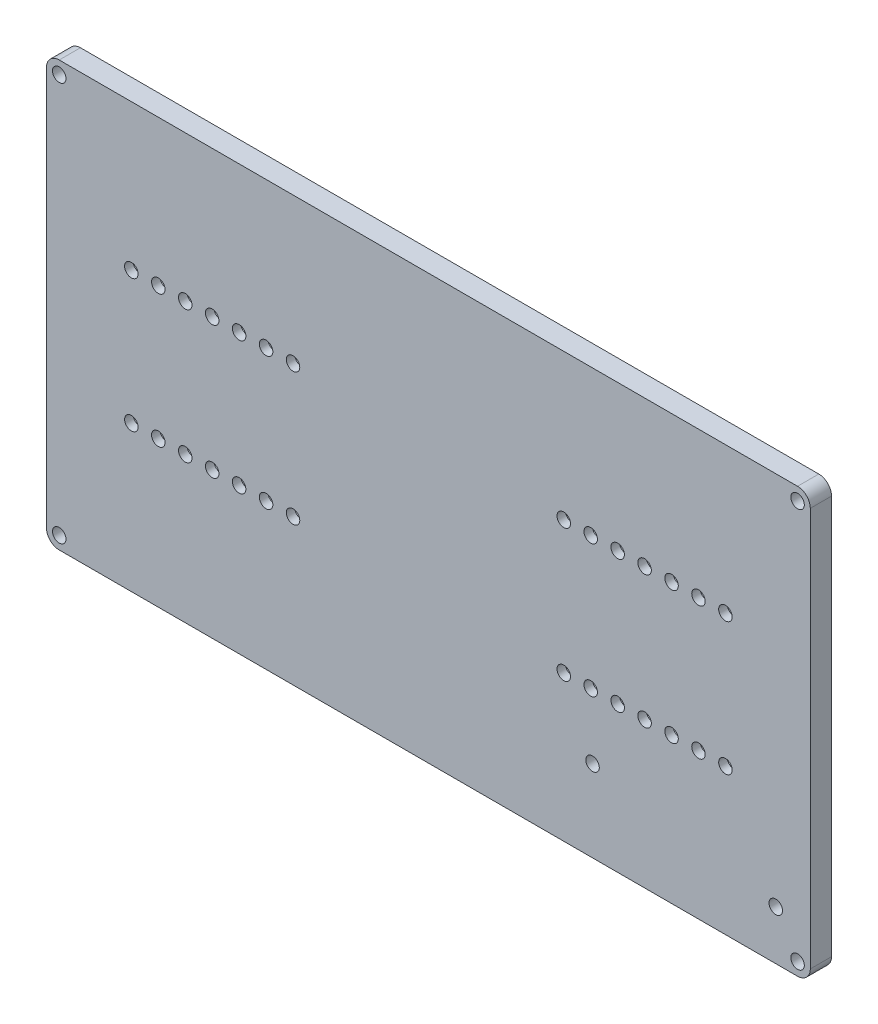
from build123d import *

# Parameters (mm, degrees)
SKETCH1_W                = 180
SKETCH1_H                = 100
BOSS_EXTRUDE1_DEPTH      = 5
SKETCH2_R                = 1.59
CUT_EXTRUDE1_DEPTH       = 6
LPATTERN1_COUNT          = 7
LPATTERN1_PITCH          = 6.35
LPATTERN1_COUNT_DIR2     = 2
LPATTERN1_PITCH_DIR2     = 31.24
MIRROR1_COPY_1_SKETCH_R  = 1.59
MIRROR1_COPY_1_DEPTH     = 6
MIRROR1_COPY_2_SKETCH_R  = 1.59
MIRROR1_COPY_2_DEPTH     = 6
MIRROR1_COPY_3_SKETCH_R  = 1.59
MIRROR1_COPY_3_DEPTH     = 6
MIRROR1_COPY_4_SKETCH_R  = 1.59
MIRROR1_COPY_4_DEPTH     = 6
MIRROR1_COPY_5_SKETCH_R  = 1.59
MIRROR1_COPY_5_DEPTH     = 6
MIRROR1_COPY_6_SKETCH_R  = 1.59
MIRROR1_COPY_6_DEPTH     = 6
MIRROR1_COPY_7_SKETCH_R  = 1.59
MIRROR1_COPY_7_DEPTH     = 6
MIRROR1_COPY_8_SKETCH_R  = 1.59
MIRROR1_COPY_8_DEPTH     = 6
MIRROR1_COPY_9_SKETCH_R  = 1.59
MIRROR1_COPY_9_DEPTH     = 6
MIRROR1_COPY_10_SKETCH_R = 1.59
MIRROR1_COPY_10_DEPTH    = 6
MIRROR1_COPY_11_SKETCH_R = 1.59
MIRROR1_COPY_11_DEPTH    = 6
MIRROR1_COPY_12_SKETCH_R = 1.59
MIRROR1_COPY_12_DEPTH    = 6
MIRROR1_COPY_13_SKETCH_R = 1.59
MIRROR1_COPY_13_DEPTH    = 6
SKETCH4_W                = 44.1
SKETCH4_H                = 5.2
CUT_EXTRUDE3_DEPTH       = 3
MIRROR5_COPY_1_SKETCH_W  = 44.1
MIRROR5_COPY_1_SKETCH_H  = 5.2
MIRROR5_COPY_1_DEPTH     = 3
FILLET1_R                = 1
FILLET2_R                = 3
SKETCH5_R                = 3
BOSS_EXTRUDE3_DEPTH      = 3
SKETCH11_R               = 1.59
CUT_EXTRUDE5_DEPTH       = 1
CUT_EXTRUDE5_DEPTH_BACK  = 9
SKETCH12_R               = 1.59
CUT_EXTRUDE6_DEPTH       = 4
CUT_EXTRUDE6_DEPTH_BACK  = 6
SKETCH14_R               = 3
CUT_EXTRUDE7_DEPTH       = 4
CUT_EXTRUDE8_DEPTH       = 0.4


with BuildPart() as part:
    # Sketch1 → Boss-Extrude1 (new body)
    with BuildSketch(Plane.XY):
        Rectangle(SKETCH1_W, SKETCH1_H)
    extrude(amount=BOSS_EXTRUDE1_DEPTH)

    # Sketch2 → Cut-Extrude1 (cut, through all)
    with BuildSketch(Plane.XY.offset(5)):
        with Locations((-70, 15.62)):
            Circle(SKETCH2_R)
    cut_extrude1 = extrude(amount=-CUT_EXTRUDE1_DEPTH, mode=Mode.SUBTRACT)

    # LPattern1: Cut-Extrude1 7 × 2
    with Locations(*[(i * LPATTERN1_PITCH, -j * LPATTERN1_PITCH_DIR2, 0) for i in range(LPATTERN1_COUNT) for j in range(LPATTERN1_COUNT_DIR2) if (i, j) != (0, 0)]):
        add(cut_extrude1, mode=Mode.SUBTRACT)

    # Mirror1: Cut-Extrude1 across plane
    add(cut_extrude1.mirror(Plane(origin=(0, 0, 0), x_dir=(0, 0, 1), z_dir=(1, 0, 0))), mode=Mode.SUBTRACT)

    # Mirror1 copy 1 sketch → Mirror1 copy 1 (cut, through all)
    with BuildSketch(Plane(origin=(0, -31.24, 5), x_dir=(-1, 0, 0), z_dir=(0, 0, 1))):
        with Locations((-70, -15.62)):
            Circle(MIRROR1_COPY_1_SKETCH_R)
    extrude(amount=-MIRROR1_COPY_1_DEPTH, mode=Mode.SUBTRACT)

    # Mirror1 copy 2 sketch → Mirror1 copy 2 (cut, through all)
    with BuildSketch(Plane(origin=(-6.35, 0, 5), x_dir=(-1, 0, 0), z_dir=(0, 0, 1))):
        with Locations((-70, -15.62)):
            Circle(MIRROR1_COPY_2_SKETCH_R)
    extrude(amount=-MIRROR1_COPY_2_DEPTH, mode=Mode.SUBTRACT)

    # Mirror1 copy 3 sketch → Mirror1 copy 3 (cut, through all)
    with BuildSketch(Plane(origin=(-6.35, -31.24, 5), x_dir=(-1, 0, 0), z_dir=(0, 0, 1))):
        with Locations((-70, -15.62)):
            Circle(MIRROR1_COPY_3_SKETCH_R)
    extrude(amount=-MIRROR1_COPY_3_DEPTH, mode=Mode.SUBTRACT)

    # Mirror1 copy 4 sketch → Mirror1 copy 4 (cut, through all)
    with BuildSketch(Plane(origin=(-12.7, 0, 5), x_dir=(-1, 0, 0), z_dir=(0, 0, 1))):
        with Locations((-70, -15.62)):
            Circle(MIRROR1_COPY_4_SKETCH_R)
    extrude(amount=-MIRROR1_COPY_4_DEPTH, mode=Mode.SUBTRACT)

    # Mirror1 copy 5 sketch → Mirror1 copy 5 (cut, through all)
    with BuildSketch(Plane(origin=(-12.7, -31.24, 5), x_dir=(-1, 0, 0), z_dir=(0, 0, 1))):
        with Locations((-70, -15.62)):
            Circle(MIRROR1_COPY_5_SKETCH_R)
    extrude(amount=-MIRROR1_COPY_5_DEPTH, mode=Mode.SUBTRACT)

    # Mirror1 copy 6 sketch → Mirror1 copy 6 (cut, through all)
    with BuildSketch(Plane(origin=(-19.05, 0, 5), x_dir=(-1, 0, 0), z_dir=(0, 0, 1))):
        with Locations((-70, -15.62)):
            Circle(MIRROR1_COPY_6_SKETCH_R)
    extrude(amount=-MIRROR1_COPY_6_DEPTH, mode=Mode.SUBTRACT)

    # Mirror1 copy 7 sketch → Mirror1 copy 7 (cut, through all)
    with BuildSketch(Plane(origin=(-19.05, -31.24, 5), x_dir=(-1, 0, 0), z_dir=(0, 0, 1))):
        with Locations((-70, -15.62)):
            Circle(MIRROR1_COPY_7_SKETCH_R)
    extrude(amount=-MIRROR1_COPY_7_DEPTH, mode=Mode.SUBTRACT)

    # Mirror1 copy 8 sketch → Mirror1 copy 8 (cut, through all)
    with BuildSketch(Plane(origin=(-25.4, 0, 5), x_dir=(-1, 0, 0), z_dir=(0, 0, 1))):
        with Locations((-70, -15.62)):
            Circle(MIRROR1_COPY_8_SKETCH_R)
    extrude(amount=-MIRROR1_COPY_8_DEPTH, mode=Mode.SUBTRACT)

    # Mirror1 copy 9 sketch → Mirror1 copy 9 (cut, through all)
    with BuildSketch(Plane(origin=(-25.4, -31.24, 5), x_dir=(-1, 0, 0), z_dir=(0, 0, 1))):
        with Locations((-70, -15.62)):
            Circle(MIRROR1_COPY_9_SKETCH_R)
    extrude(amount=-MIRROR1_COPY_9_DEPTH, mode=Mode.SUBTRACT)

    # Mirror1 copy 10 sketch → Mirror1 copy 10 (cut, through all)
    with BuildSketch(Plane(origin=(-31.75, 0, 5), x_dir=(-1, 0, 0), z_dir=(0, 0, 1))):
        with Locations((-70, -15.62)):
            Circle(MIRROR1_COPY_10_SKETCH_R)
    extrude(amount=-MIRROR1_COPY_10_DEPTH, mode=Mode.SUBTRACT)

    # Mirror1 copy 11 sketch → Mirror1 copy 11 (cut, through all)
    with BuildSketch(Plane(origin=(-31.75, -31.24, 5), x_dir=(-1, 0, 0), z_dir=(0, 0, 1))):
        with Locations((-70, -15.62)):
            Circle(MIRROR1_COPY_11_SKETCH_R)
    extrude(amount=-MIRROR1_COPY_11_DEPTH, mode=Mode.SUBTRACT)

    # Mirror1 copy 12 sketch → Mirror1 copy 12 (cut, through all)
    with BuildSketch(Plane(origin=(-38.1, 0, 5), x_dir=(-1, 0, 0), z_dir=(0, 0, 1))):
        with Locations((-70, -15.62)):
            Circle(MIRROR1_COPY_12_SKETCH_R)
    extrude(amount=-MIRROR1_COPY_12_DEPTH, mode=Mode.SUBTRACT)

    # Mirror1 copy 13 sketch → Mirror1 copy 13 (cut, through all)
    with BuildSketch(Plane(origin=(-38.1, -31.24, 5), x_dir=(-1, 0, 0), z_dir=(0, 0, 1))):
        with Locations((-70, -15.62)):
            Circle(MIRROR1_COPY_13_SKETCH_R)
    extrude(amount=-MIRROR1_COPY_13_DEPTH, mode=Mode.SUBTRACT)

    # Sketch4 → Cut-Extrude3 (cut)
    with BuildSketch(Plane(origin=(0, 0, 0), x_dir=(-1, 0, 0), z_dir=(0, 0, -1))):
        with Locations((50.95, 15.62)):
            Rectangle(SKETCH4_W, SKETCH4_H)
    cut_extrude3 = extrude(amount=-CUT_EXTRUDE3_DEPTH, mode=Mode.SUBTRACT)

    # Mirror4: Cut-Extrude3 across plane
    add(cut_extrude3.mirror(Plane.ZX), mode=Mode.SUBTRACT)

    # Mirror5: Cut-Extrude3 across plane
    add(cut_extrude3.mirror(Plane(origin=(0, 0, 0), x_dir=(0, 0, 1), z_dir=(1, 0, 0))), mode=Mode.SUBTRACT)

    # Mirror5 copy 1 sketch → Mirror5 copy 1 (cut)
    with BuildSketch(Plane(origin=(0, 0, 0), x_dir=(1, 0, 0), z_dir=(0, 0, -1))):
        with Locations((50.95, 15.62)):
            Rectangle(MIRROR5_COPY_1_SKETCH_W, MIRROR5_COPY_1_SKETCH_H)
    extrude(amount=-MIRROR5_COPY_1_DEPTH, mode=Mode.SUBTRACT)

    # Fillet1
    fillet1_edges = [part.edges().sort_by_distance(p)[0] for p in [
        (-28.9, 13.02, 1.5),
        (-28.9, 18.22, 1.5),
        (-73, 18.22, 1.5),
        (-73, 13.02, 1.5),
        (-28.9, -18.22, 1.5),
        (-28.9, -13.02, 1.5),
        (-73, -13.02, 1.5),
        (-73, -18.22, 1.5),
        (28.9, -13.02, 1.5),
        (28.9, -18.22, 1.5),
        (73, -18.22, 1.5),
        (73, -13.02, 1.5),
        (28.9, 18.22, 1.5),
        (28.9, 13.02, 1.5),
        (73, 13.02, 1.5),
        (73, 18.22, 1.5),
    ]]
    fillet(fillet1_edges, radius=FILLET1_R)

    # Fillet2
    fillet2_edges = [part.edges().sort_by_distance(p)[0] for p in [
        (-90, 50, 2.5),
        (90, 50, 2.5),
        (90, -50, 2.5),
        (-90, -50, 2.5),
    ]]
    fillet(fillet2_edges, radius=FILLET2_R)

    # Sketch5 → Boss-Extrude3 (add)
    with BuildSketch(Plane(origin=(0, 0, 0), x_dir=(-1, 0, 0), z_dir=(0, 0, -1))):
        with Locations((-81.863597073, -38.398306499)):
            Circle(SKETCH5_R)
        with Locations((-38.683597073, -30.778306499)):
            Circle(SKETCH5_R)
    extrude(amount=BOSS_EXTRUDE3_DEPTH)

    # Sketch11 → Cut-Extrude5 (cut, two sides)
    with BuildSketch(Plane(origin=(0, 0, -3), x_dir=(-1, 0, 0), z_dir=(0, 0, -1))) as cut_extrude5_sk:
        with Locations((-81.863597073, -38.398306499)):
            Circle(SKETCH11_R)
        with Locations((-38.683597073, -30.778306499)):
            Circle(SKETCH11_R)
    extrude(amount=CUT_EXTRUDE5_DEPTH, mode=Mode.SUBTRACT)
    extrude(cut_extrude5_sk.sketch, amount=-CUT_EXTRUDE5_DEPTH_BACK, mode=Mode.SUBTRACT)

    # Sketch12 → Cut-Extrude6 (cut, two sides)
    with BuildSketch(Plane(origin=(0, 0, 0), x_dir=(-1, 0, 0), z_dir=(0, 0, -1))) as cut_extrude6_sk:
        with Locations((-87, -47)):
            Circle(SKETCH12_R)
        with Locations((-87, 47)):
            Circle(SKETCH12_R)
        with Locations((87, 47)):
            Circle(SKETCH12_R)
        with Locations((87, -47)):
            Circle(SKETCH12_R)
    extrude(amount=CUT_EXTRUDE6_DEPTH, mode=Mode.SUBTRACT)
    extrude(cut_extrude6_sk.sketch, amount=-CUT_EXTRUDE6_DEPTH_BACK, mode=Mode.SUBTRACT)

    # Sketch14 → Cut-Extrude7 (cut)
    with BuildSketch(Plane(origin=(0, 0, 0), x_dir=(-1, 0, 0), z_dir=(0, 0, -1))):
        with BuildLine():
            ThreePointArc((-85.348265181, 49), (-84.514110663, 47.740663297), (-84.522995338, 46.230145586))
            Line((-84.522995338, 46.230145586), (-34.525491807, 19.22))
            Line((-34.525491807, 19.22), (-29.9, 19.22))
            ThreePointArc((-29.9, 19.22), (-28.485786438, 18.634213562), (-27.9, 17.22))
            Line((-27.9, 17.22), (-27.9, 15.640711323))
            Line((-27.9, 15.640711323), (-0.79625872, 0.998460287))
            Line((-0.79625872, 0.998460287), (0.796309268, 0.998487594))
            Line((0.796309268, 0.998487594), (27.9, 15.640711323))
            Line((27.9, 15.640711323), (27.9, 17.22))
            ThreePointArc((27.9, 17.22), (28.485786438, 18.634213562), (29.9, 19.22))
            Line((29.9, 19.22), (34.525491807, 19.22))
            Line((34.525491807, 19.22), (84.526476888, 46.232026423))
            ThreePointArc((84.526476888, 46.232026423), (84.518614054, 47.742175039), (85.354369422, 49))
            Line((85.354369422, 49), (-85.348265181, 49))
        make_face()
        with BuildLine():
            Line((36.62940181, -19.22), (85.00178239, -45.352205601))
            ThreePointArc((85.00178239, -45.352205601), (87.001401699, -44.410000379), (89, -45.354369422))
            Line((89, -45.354369422), (89, -1))
            Line((89, -1), (2.905751439, -1.001476236))
            Line((2.905751439, -1.001476236), (27.9, -14.504116263))
            Line((27.9, -14.504116263), (27.9, -14.02))
            ThreePointArc((27.9, -14.02), (28.485786438, -12.605786438), (29.9, -12.02))
            Line((29.9, -12.02), (72, -12.02))
            ThreePointArc((72, -12.02), (73.414213562, -12.605786438), (74, -14.02))
            Line((74, -14.02), (74, -17.22))
            ThreePointArc((74, -17.22), (73.414213562, -18.634213562), (72, -19.22))
            Line((72, -19.22), (36.62940181, -19.22))
        make_face()
        with BuildLine():
            ThreePointArc((89, 45.354369422), (87.001401699, 44.410000379), (85.00178239, 45.352205601))
            Line((85.00178239, 45.352205601), (36.62940181, 19.22))
            Line((36.62940181, 19.22), (72, 19.22))
            ThreePointArc((72, 19.22), (73.414213562, 18.634213562), (74, 17.22))
            Line((74, 17.22), (74, 14.02))
            ThreePointArc((74, 14.02), (73.414213562, 12.605786438), (72, 12.02))
            Line((72, 12.02), (29.9, 12.02))
            ThreePointArc((29.9, 12.02), (28.485786438, 12.605786438), (27.9, 14.02))
            Line((27.9, 14.02), (27.9, 14.504116263))
            Line((27.9, 14.504116263), (2.900286051, 0.99852367))
            Line((2.900286051, 0.99852367), (89, 1))
            Line((89, 1), (89, 45.354369422))
        make_face()
        with BuildLine():
            Line((-2.9059359, -1.001575888), (-89, -1.003052121))
            Line((-89, -1.003052121), (-89, -45.354369422))
            ThreePointArc((-89, -45.354369422), (-87.001401699, -44.410000379), (-85.00178239, -45.352205601))
            Line((-85.00178239, -45.352205601), (-36.62940181, -19.22))
            Line((-36.62940181, -19.22), (-72, -19.22))
            ThreePointArc((-72, -19.22), (-73.414213562, -18.634213562), (-74, -17.22))
            Line((-74, -17.22), (-74, -14.02))
            ThreePointArc((-74, -14.02), (-73.414213562, -12.605786438), (-72, -12.02))
            Line((-72, -12.02), (-29.9, -12.02))
            ThreePointArc((-29.9, -12.02), (-28.485786438, -12.605786438), (-27.9, -14.02))
            Line((-27.9, -14.02), (-27.9, -14.504116263))
            Line((-27.9, -14.504116263), (-2.9059359, -1.001575888))
        make_face()
        with Locations((-81.863597073, -38.398306499)):
            Circle(SKETCH14_R, mode=Mode.SUBTRACT)
        with BuildLine():
            Line((-34.525491807, -19.22), (-84.526476888, -46.232026423))
            ThreePointArc((-84.526476888, -46.232026423), (-84.518614054, -47.742175039), (-85.354369422, -49))
            Line((-85.354369422, -49), (85.354369422, -49))
            ThreePointArc((85.354369422, -49), (84.518614054, -47.742175039), (84.526476888, -46.232026423))
            Line((84.526476888, -46.232026423), (34.525491807, -19.22))
            Line((34.525491807, -19.22), (29.9, -19.22))
            ThreePointArc((29.9, -19.22), (28.485786438, -18.634213562), (27.9, -17.22))
            Line((27.9, -17.22), (27.9, -15.640711323))
            Line((27.9, -15.640711323), (0.801908211, -1.00151231))
            Line((0.801908211, -1.00151231), (-0.801959117, -1.001539811))
            Line((-0.801959117, -1.001539811), (-27.9, -15.640711323))
            Line((-27.9, -15.640711323), (-27.9, -17.22))
            ThreePointArc((-27.9, -17.22), (-28.485786438, -18.634213562), (-29.9, -19.22))
            Line((-29.9, -19.22), (-34.525491807, -19.22))
        make_face()
        with Locations((-38.683597073, -30.778306499)):
            Circle(SKETCH14_R, mode=Mode.SUBTRACT)
        with BuildLine():
            ThreePointArc((-84.99830084, 45.350324763), (-86.998664988, 44.406117556), (-89, 45.348265181))
            Line((-89, 45.348265181), (-89, 0.99694788))
            Line((-89, 0.99694788), (-2.900101948, 0.998424213))
            Line((-2.900101948, 0.998424213), (-27.9, 14.504116263))
            Line((-27.9, 14.504116263), (-27.9, 14.02))
            ThreePointArc((-27.9, 14.02), (-28.485786438, 12.605786438), (-29.9, 12.02))
            Line((-29.9, 12.02), (-72, 12.02))
            ThreePointArc((-72, 12.02), (-73.414213562, 12.605786438), (-74, 14.02))
            Line((-74, 14.02), (-74, 17.22))
            ThreePointArc((-74, 17.22), (-73.414213562, 18.634213562), (-72, 19.22))
            Line((-72, 19.22), (-36.62940181, 19.22))
            Line((-36.62940181, 19.22), (-84.99830084, 45.350324763))
        make_face()
    extrude(amount=-CUT_EXTRUDE7_DEPTH, mode=Mode.SUBTRACT)

    # Sketch15 → Cut-Extrude8 (cut)
    with BuildSketch(Plane(origin=(0, 0, 4), x_dir=(-1, 0, 0), z_dir=(0, 0, -1))):
        with BuildLine():
            Line((69.307829408, 47.924379364), (70.006425423, 46.292812335))
            add(Edge.make_bspline(
                [(70.006425423, 46.292812335), (70.023413138, 46.255584111), (70.056423518, 46.183242549), (70.123321318, 46.087798721), (70.198897769, 46.005525039), (70.285383741, 45.937760562), (70.38281428, 45.887648882), (70.487055268, 45.848851983), (70.600032397, 45.82793733), (70.677771544, 45.824622904), (70.717476147, 45.822930089)],
                knots=[0, 0, 0, 0, 0.000122539, 0.000238117, 0.000347875, 0.000456812, 0.000565708, 0.000675308, 0.000789446, 0.000908596, 0.000908596, 0.000908596, 0.000908596], degree=3))
            Line((70.717476147, 45.822930089), (70.902032307, 45.822930089))
            Line((70.902032307, 45.822930089), (70.902032307, 47.924379364))
            Line((70.902032307, 47.924379364), (71.844061292, 47.924379364))
            Line((71.844061292, 47.924379364), (71.844061292, 42.924379364))
            Line((71.844061292, 42.924379364), (70.360818538, 42.924379364))
            add(Edge.make_bspline(
                [(70.360818538, 42.924379364), (70.292103053, 42.925178616), (70.157928963, 42.926739237), (69.96186968, 42.94092441), (69.77549819, 42.961980609), (69.599407648, 42.991781593), (69.434261551, 43.032523028), (69.28082362, 43.083530321), (69.140929363, 43.149392718), (69.011975622, 43.222920639), (68.897143192, 43.311124209), (68.797760175, 43.412590419), (68.710034593, 43.524774987), (68.637079658, 43.650188575), (68.580172147, 43.79006751), (68.540003707, 43.944209677), (68.514498007, 44.112769634), (68.512015333, 44.230139399), (68.510727959, 44.291000741)],
                knots=[0, 0, 0, 0, 0.000206119, 0.000402468, 0.000589398, 0.000768655, 0.000937815, 0.001099298, 0.001252791, 0.00140096, 0.001543861, 0.001685573, 0.00182599, 0.001970083, 0.002119368, 0.002277563, 0.002446977, 0.00262944, 0.00262944, 0.00262944, 0.00262944], degree=3))
            add(Edge.make_bspline(
                [(68.510727959, 44.291000741), (68.511829759, 44.335210174), (68.513974844, 44.421281108), (68.530175773, 44.546331529), (68.555796025, 44.664111342), (68.593447394, 44.774466143), (68.641239278, 44.877241103), (68.696543651, 44.973369921), (68.761960294, 45.060728198), (68.834242243, 45.141617801), (68.915341938, 45.214058038), (69.00269506, 45.279564842), (69.095722831, 45.339190645), (69.195903588, 45.389612471), (69.300611184, 45.43381841), (69.409841059, 45.469697834), (69.5224247, 45.499781198), (69.599453874, 45.513616832), (69.63844535, 45.520620306)],
                knots=[0, 0, 0, 0, 0.000132594, 0.000258146, 0.000377639, 0.000493649, 0.000607128, 0.000717236, 0.000825707, 0.000933936, 0.001042164, 0.001151313, 0.001261252, 0.001373161, 0.001487344, 0.001601919, 0.001717813, 0.001836613, 0.001836613, 0.001836613, 0.001836613], degree=3))
            add(Edge.make_bspline(
                [(69.63844535, 45.520620306), (69.608210759, 45.528547284), (69.546695241, 45.54467557), (69.460138778, 45.591053217), (69.376890617, 45.651381716), (69.297709085, 45.729200765), (69.221567746, 45.825408002), (69.144930698, 45.939631583), (69.069308399, 46.074015626), (69.022319982, 46.171378899), (68.997593901, 46.22261306)],
                knots=[0, 0, 0, 0, 9.3484e-05, 0.000190203, 0.000292344, 0.00040124, 0.000522014, 0.000659874, 0.000813514, 0.000984157, 0.000984157, 0.000984157, 0.000984157], degree=3))
            Line((68.997593901, 46.22261306), (68.203889191, 47.924379364))
            Line((68.203889191, 47.924379364), (69.307829408, 47.924379364))
        make_face()
        with BuildLine():
            add(Edge.make_bspline(
                [(69.525220712, 44.392902915), (69.525760871, 44.36418368), (69.526810236, 44.308390911), (69.538088676, 44.227816546), (69.557607575, 44.153523559), (69.583417585, 44.085361595), (69.616251193, 44.02322873), (69.65779176, 43.968101394), (69.706974303, 43.919481004), (69.7627176, 43.875617247), (69.827412944, 43.839691355), (69.898787237, 43.808297189), (69.97734232, 43.780549023), (70.06374609, 43.760342742), (70.156714273, 43.740831621), (70.258035952, 43.731254937), (70.366319567, 43.72220884), (70.441183912, 43.721728147), (70.479704408, 43.721480813)],
                knots=[0, 0, 0, 0, 8.6118e-05, 0.000167301, 0.000243372, 0.000316127, 0.000385528, 0.000453462, 0.000522316, 0.000592524, 0.000665552, 0.000743611, 0.000826327, 0.000915026, 0.001009621, 0.001111025, 0.001220009, 0.001335521, 0.001335521, 0.001335521, 0.001335521], degree=3))
            Line((70.479704408, 43.721480813), (70.902032307, 43.721480813))
            Line((70.902032307, 43.721480813), (70.902032307, 45.098292407))
            Line((70.902032307, 45.098292407), (70.511407307, 45.098292407))
            add(Edge.make_bspline(
                [(70.511407307, 45.098292407), (70.440292922, 45.096392144), (70.303971537, 45.092749469), (70.139201046, 45.062992318), (70.019130363, 45.030069633), (69.937804774, 44.99897449), (69.862910767, 44.963050613), (69.79452173, 44.921023202), (69.733404991, 44.873553408), (69.678959476, 44.820774009), (69.632867793, 44.761923461), (69.593789165, 44.697843063), (69.563010613, 44.628647656), (69.541930986, 44.55425769), (69.527514831, 44.475354999), (69.525999687, 44.420899763), (69.525220712, 44.392902915)],
                knots=[0, 0, 0, 0, 0.000213163, 0.000408619, 0.00050038, 0.000586386, 0.000669435, 0.000749248, 0.000826706, 0.000901167, 0.000976144, 0.001050321, 0.001125852, 0.001202527, 0.001281825, 0.001365734, 0.001365734, 0.001365734, 0.001365734], degree=3))
        make_face(mode=Mode.SUBTRACT)
        Polygon((67.351307669, 47.924379364), (67.351307669, 42.924379364), (64.307829408, 42.924379364), (64.307829408, 43.721480813), (66.409278683, 43.721480813), (66.409278683, 44.953364871), (64.380293176, 44.953364871), (64.380293176, 45.75046632), (66.409278683, 45.75046632), (66.409278683, 47.127277915), (64.307829408, 47.127277915), (64.307829408, 47.924379364), align=None)
        Polygon((61.074133756, 47.924379364), (62.31960477, 47.924379364), (63.836814915, 42.924379364), (62.770238828, 42.924379364), (61.932376509, 45.93502248), (61.662901872, 46.92234132), (61.385501509, 45.878410161), (60.562358394, 42.924379364), (59.561452596, 42.924379364), align=None)
        Polygon((54.742612017, 47.924379364), (54.742612017, 47.127277915), (53.438264191, 47.127277915), (53.438264191, 43.908301465), (54.573907307, 44.518582262), (54.887539553, 43.721480813), (53.266162741, 42.924379364), (52.496235205, 42.924379364), (52.496235205, 47.127277915), (51.409278683, 47.127277915), (51.409278683, 47.924379364), align=None)
    extrude(amount=-CUT_EXTRUDE8_DEPTH, mode=Mode.SUBTRACT)


solid = part.part
